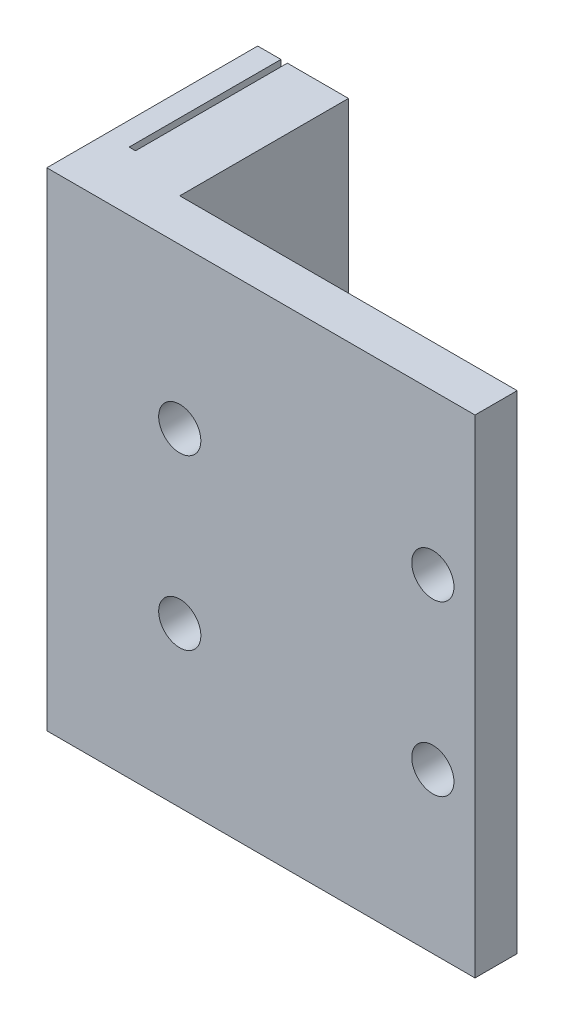
from build123d import *

# Parameters (mm, degrees)
SKETCH1_R            = 1.25
BOSS_EXTRUDE1_DEPTH  = 2.5
SKETCH3_W            = 12.5
SKETCH3_H            = 28.9
BOSS_EXTRUDE2_DEPTH  = 5.38
CUT_EXTRUDE1_DEPTH   = 9
LPATTERN1_COUNT      = 4
LPATTERN1_PITCH      = 10
LPATTERN1_COUNT_DIR2 = 2
LPATTERN1_PITCH_DIR2 = 10


with BuildPart() as part:
    # Sketch1 → Boss-Extrude1 (new body)
    with BuildSketch(Plane.XY):
        Polygon((9.79, -14.45), (-8.795857864, -14.45), (-10, -14.45), (-10, 14.45), (-9.79, 14.45), (8.795857864, 14.45), (10, 14.45), (10, -14.45), align=None)
        with Locations((-7.5, -5)):
            Circle(SKETCH1_R, mode=Mode.SUBTRACT)
        with Locations((-7.5, 5)):
            Circle(SKETCH1_R, mode=Mode.SUBTRACT)
        with Locations((7.5, 5)):
            Circle(SKETCH1_R, mode=Mode.SUBTRACT)
        with Locations((7.5, -5)):
            Circle(SKETCH1_R, mode=Mode.SUBTRACT)
    extrude(amount=BOSS_EXTRUDE1_DEPTH)

    # Sketch3 → Boss-Extrude2 (add)
    with BuildSketch(Plane.ZY.offset(10)):
        with Locations((-3.75, 0)):
            Rectangle(SKETCH3_W, SKETCH3_H)
    extrude(amount=BOSS_EXTRUDE2_DEPTH)

    # Sketch4 → Cut-Extrude1 (cut)
    with BuildSketch(Plane(origin=(0, 0, -10), x_dir=(-1, 0, 0), z_dir=(0, 0, -1))):
        with BuildLine():
            Line((13.62129958, 14.447528029), (13.62129958, 14.194772629))
            ThreePointArc((13.62129958, 14.194772629), (13.584011291, 14.095850288), (13.49070263, 14.046155824))
            ThreePointArc((13.49070263, 14.046155824), (13.278327951, 13.994947975), (13.081809662, 13.899523608))
            ThreePointArc((13.081809662, 13.899523608), (12.85675958, 13.447530026), (13.081809666, 12.995536447))
            ThreePointArc((13.081809666, 12.995536447), (13.278327608, 12.9001091), (13.490702635, 12.848898474))
            ThreePointArc((13.490702635, 12.848898474), (13.584017776, 12.799196632), (13.62129958, 12.700262029))
            Line((13.62129958, 12.700262029), (13.62129958, 12.194776629))
            ThreePointArc((13.62129958, 12.194776629), (13.584011291, 12.095854288), (13.49070263, 12.046159824))
            ThreePointArc((13.49070263, 12.046159824), (13.278327951, 11.994951975), (13.081809662, 11.899527608))
            ThreePointArc((13.081809662, 11.899527608), (12.85675958, 11.447534026), (13.081809666, 10.995540447))
            ThreePointArc((13.081809666, 10.995540447), (13.278327608, 10.9001131), (13.490702635, 10.848902474))
            ThreePointArc((13.490702635, 10.848902474), (13.584017776, 10.799200632), (13.62129958, 10.700266029))
            Line((13.62129958, 10.700266029), (13.62129958, 10.194780629))
            ThreePointArc((13.62129958, 10.194780629), (13.584011291, 10.095858288), (13.49070263, 10.046163824))
            ThreePointArc((13.49070263, 10.046163824), (13.278326417, 9.994943722), (13.081809662, 9.899506208))
            ThreePointArc((13.081809662, 9.899506208), (12.85675958, 9.447512626), (13.081809666, 8.995519047))
            ThreePointArc((13.081809666, 8.995519047), (13.278327608, 8.9000917), (13.490702635, 8.848881074))
            ThreePointArc((13.490702635, 8.848881074), (13.584009392, 8.799188772), (13.62129958, 8.700270029))
            Line((13.62129958, 8.700270029), (13.62129958, 8.194759229))
            ThreePointArc((13.62129958, 8.194759229), (13.584011291, 8.095836888), (13.49070263, 8.046142424))
            ThreePointArc((13.49070263, 8.046142424), (13.278327951, 7.994934575), (13.081809662, 7.899510208))
            ThreePointArc((13.081809662, 7.899510208), (12.85675958, 7.447516626), (13.081809666, 6.995523047))
            ThreePointArc((13.081809666, 6.995523047), (13.278327608, 6.9000957), (13.490702635, 6.848885074))
            ThreePointArc((13.490702635, 6.848885074), (13.584009392, 6.799192772), (13.62129958, 6.700274029))
            Line((13.62129958, 6.700274029), (13.62129958, 6.194763229))
            ThreePointArc((13.62129958, 6.194763229), (13.584011291, 6.095840888), (13.49070263, 6.046146424))
            ThreePointArc((13.49070263, 6.046146424), (13.278327951, 5.994938575), (13.081809662, 5.899514208))
            ThreePointArc((13.081809662, 5.899514208), (12.85675958, 5.447520626), (13.081809666, 4.995527047))
            ThreePointArc((13.081809666, 4.995527047), (13.278327608, 4.9000997), (13.490702635, 4.848889074))
            ThreePointArc((13.490702635, 4.848889074), (13.584009392, 4.799196772), (13.62129958, 4.700278029))
            Line((13.62129958, 4.700278029), (13.62129958, 4.447522629))
            Line((13.62129958, 4.447522629), (14.00229958, 4.447522629))
            Line((14.00229958, 4.447522629), (14.00229958, 14.447528029))
            Line((14.00229958, 14.447528029), (13.62129958, 14.447528029))
        make_face()
    cut_extrude1 = extrude(amount=-CUT_EXTRUDE1_DEPTH, mode=Mode.SUBTRACT)

    # LPattern1: Cut-Extrude1 4 × 2
    with Locations(*[Vector(0, -1, 0) * (i * LPATTERN1_PITCH) + Vector(0, 1, 0) * (j * LPATTERN1_PITCH_DIR2) for i in range(LPATTERN1_COUNT) for j in range(LPATTERN1_COUNT_DIR2) if (i, j) != (0, 0)]):
        add(cut_extrude1, mode=Mode.SUBTRACT)


solid = part.part
